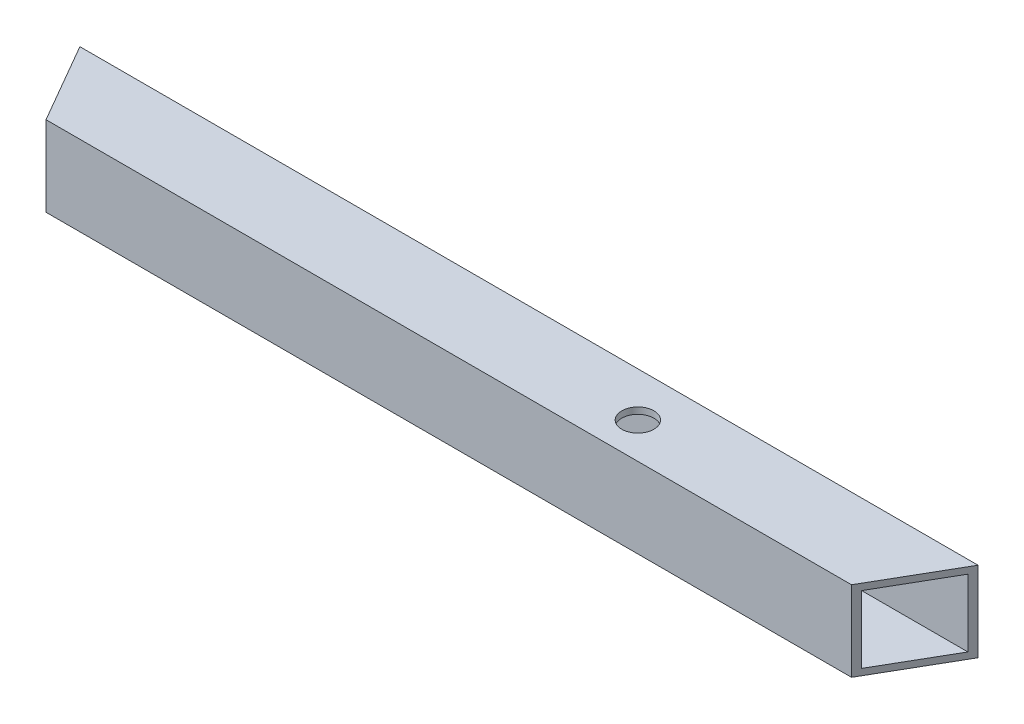
from build123d import *

# Parameters (mm, degrees)
BOSS_EXTRUDE1_DEPTH = 25
SHELL1_T            = -2
SKETCH2_R           = 5
CUT_EXTRUDE1_DEPTH  = 53


with BuildPart() as part:
    # Sketch1 → Boss-Extrude1 (new body)
    with BuildSketch(Plane(origin=(0, 0, 0), x_dir=(1, 0, 0), z_dir=(0, 1, 0))):
        Polygon((125.56624327, 217.48711306), (-125.56624327, 217.48711306), (-140, 242.48711306), (140, 242.48711306), align=None)
    extrude(amount=BOSS_EXTRUDE1_DEPTH)

    # Shell1
    shell1_openings = [part.faces().sort_by_distance(p)[0] for p in [
        (-132.783121635, 12.5, -229.98711306),
        (132.783121635, 12.5, -229.98711306),
    ]]
    offset(amount=SHELL1_T, openings=shell1_openings, kind=Kind.INTERSECTION)

    # Sketch2 → Cut-Extrude1 (cut)
    with BuildSketch(Plane(origin=(0, 25, 0), x_dir=(1, 0, 0), z_dir=(0, 1, 0))):
        with Locations((47.783121635, 228.657359562)):
            Circle(SKETCH2_R)
    extrude(amount=-CUT_EXTRUDE1_DEPTH, mode=Mode.SUBTRACT)


solid = part.part
